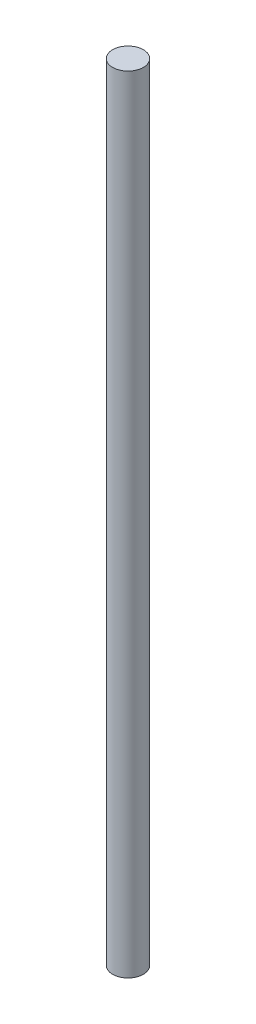
from build123d import *

# Parameters (mm, degrees)
SKETCH2_R           = 4.5
BOSS_EXTRUDE1_DEPTH = 230


with BuildPart() as part:
    # Sketch2 → Boss-Extrude1 (new body)
    with BuildSketch(Plane(origin=(0, 0, 0), x_dir=(1, 0, 0), z_dir=(0, 1, 0))):
        with Locations((-2.257755969, 0.995085038)):
            Circle(SKETCH2_R)
    extrude(amount=-BOSS_EXTRUDE1_DEPTH)


solid = part.part
